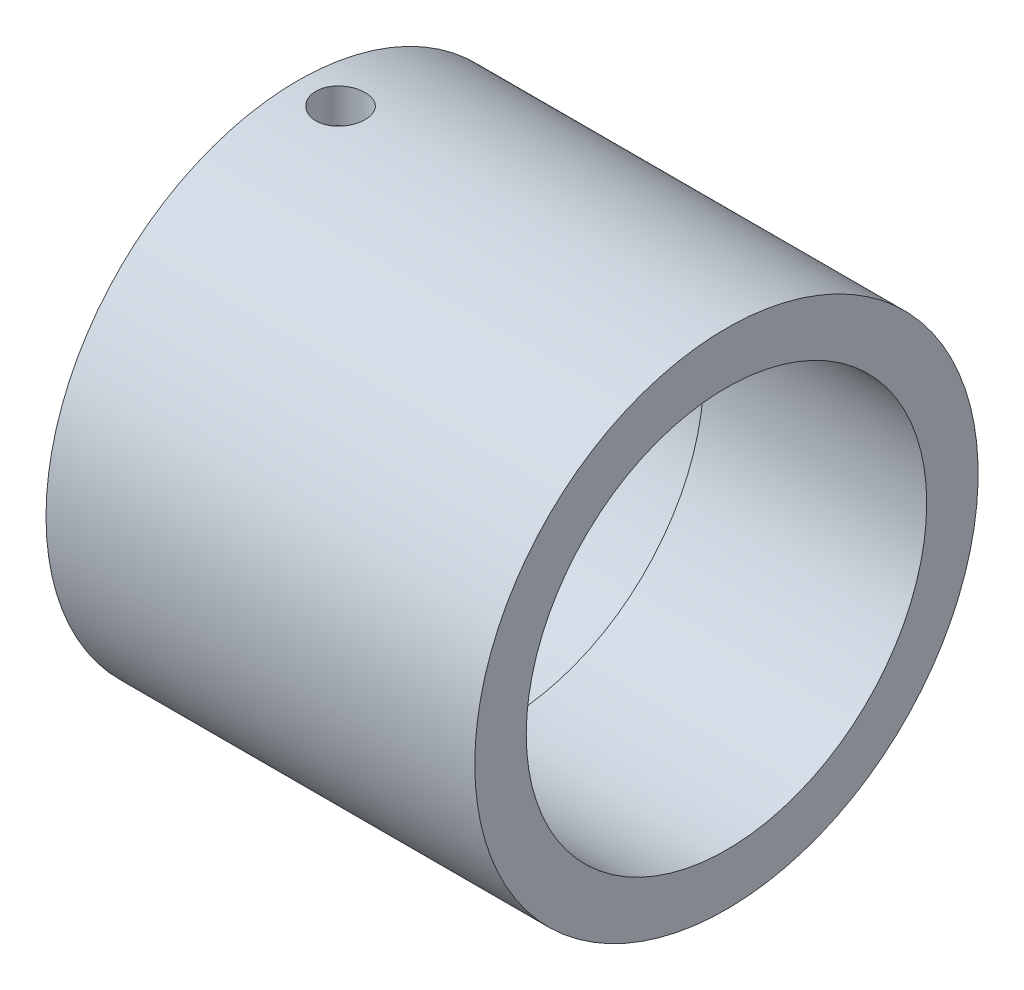
from build123d import *

# Parameters (mm, degrees)
CROQUIS4_R                 = 1.435
CORTAR_EXTRUIR1_DEPTH      = 15.675
CORTAR_EXTRUIR1_DEPTH_BACK = 15.675


with BuildPart() as part:
    # Croquis3 → Revolución1 (revolve)
    with BuildSketch(Plane(origin=(0, 0, 0), x_dir=(1, 0, 0), z_dir=(0, 1, 0))):
        Polygon((0, 11.675), (-13, 11.675), (-13, 12.675), (-25, 12.675), (-25, 14.675), (0, 14.675), align=None)
    revolve(axis=Axis((-30.367380332, 0, 0), (1, 0, 0)))

    # Croquis4 → Cortar-Extruir1 (cut, two sides)
    with BuildSketch(Plane(origin=(0, 0, 0), x_dir=(1, 0, 0), z_dir=(0, 1, 0))) as cortar_extruir1_sk:
        with Locations((-22.5, 0)):
            Circle(CROQUIS4_R)
    extrude(amount=CORTAR_EXTRUIR1_DEPTH, mode=Mode.SUBTRACT)
    extrude(cortar_extruir1_sk.sketch, amount=-CORTAR_EXTRUIR1_DEPTH_BACK, mode=Mode.SUBTRACT)


solid = part.part
